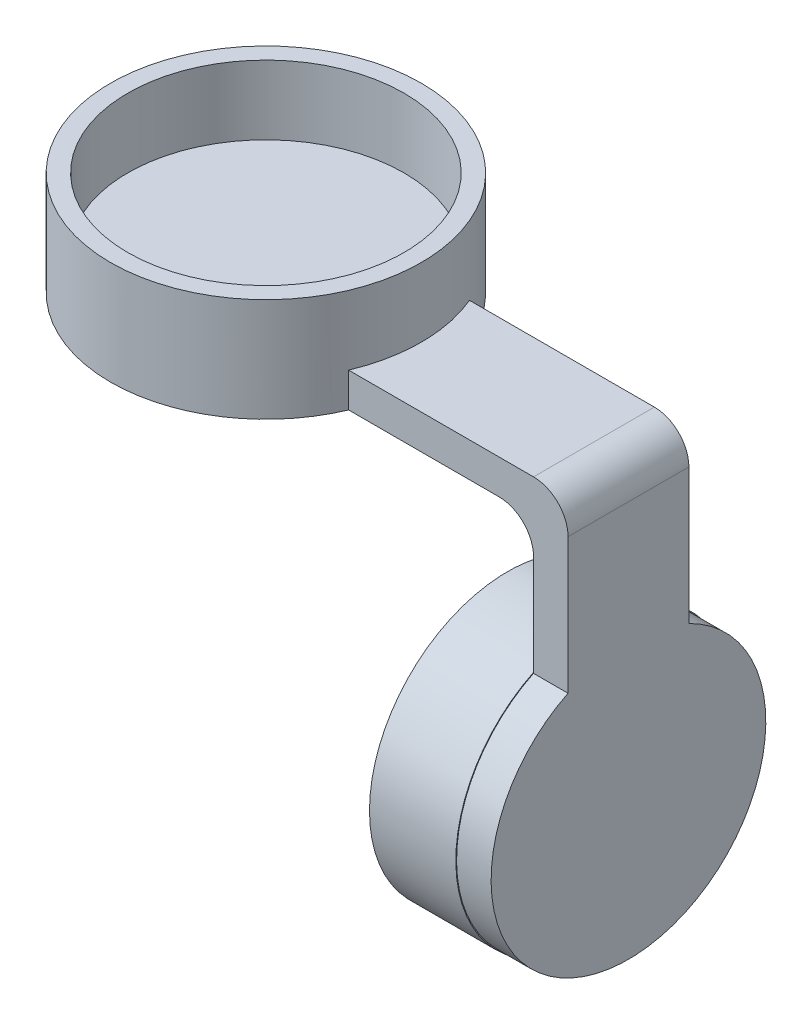
from build123d import *

# Parameters (mm, degrees)
SKETCH1_R           = 16
SKETCH1_R_2         = 14
BOSS_EXTRUDE1_DEPTH = 10
BOSS_EXTRUDE2_DEPTH = 4
BOSS_EXTRUDE3_DEPTH = 14
SKETCH4_R           = 18
BOSS_EXTRUDE4_DEPTH = 4
SKETCH5_R           = 18
SKETCH5_R_2         = 16
BOSS_EXTRUDE5_DEPTH = 8


with BuildPart() as part:
    # Sketch1 → Boss-Extrude1 (new body)
    with BuildSketch(Plane(origin=(0, 0, 0), x_dir=(0, 0, -1), z_dir=(1, 0, 0))):
        Circle(SKETCH1_R)
        Circle(SKETCH1_R_2, mode=Mode.SUBTRACT)
    extrude(amount=-BOSS_EXTRUDE1_DEPTH)

    # Sketch2 → Boss-Extrude2 (add)
    with BuildSketch(Plane(origin=(0, 0, 0), x_dir=(0, 0, -1), z_dir=(1, 0, 0))):
        with BuildLine():
            Line((-7, 14.288943502), (-7, 20))
            Line((-7, 20), (7, 20))
            Line((7, 20), (7, 14.288943502))
            ThreePointArc((7, 14.288943502), (0, -15.911439483), (-7, 14.288943502))
        make_face()
    extrude(amount=BOSS_EXTRUDE2_DEPTH)

    # Sketch3 → Boss-Extrude3 (add)
    with BuildSketch(Plane(origin=(0, 0, -7), x_dir=(-1, 0, 0), z_dir=(0, 0, -1))):
        with BuildLine():
            Line((0, 20), (-4, 20))
            Line((-4, 20), (-4, 30))
            ThreePointArc((-4, 30), (-2.828427125, 32.828427125), (0, 34))
            Line((0, 34), (38, 34))
            Line((38, 34), (38, 30))
            Line((38, 30), (4, 30))
            ThreePointArc((4, 30), (1.171572875, 28.828427125), (0, 26))
            Line((0, 26), (0, 20))
        make_face()
    extrude(amount=-BOSS_EXTRUDE3_DEPTH)

    # Sketch4 → Boss-Extrude4 (add)
    with BuildSketch(Plane(origin=(0, 34, 0), x_dir=(1, 0, 0), z_dir=(0, 1, 0))):
        with Locations((-38, 0)):
            Circle(SKETCH4_R)
    extrude(amount=-BOSS_EXTRUDE4_DEPTH)

    # Sketch5 → Boss-Extrude5 (add)
    with BuildSketch(Plane(origin=(0, 34, 0), x_dir=(1, 0, 0), z_dir=(0, 1, 0))):
        with Locations((-38, 0)):
            Circle(SKETCH5_R)
        with Locations((-38, 0)):
            Circle(SKETCH5_R_2, mode=Mode.SUBTRACT)
    extrude(amount=BOSS_EXTRUDE5_DEPTH)


solid = part.part
